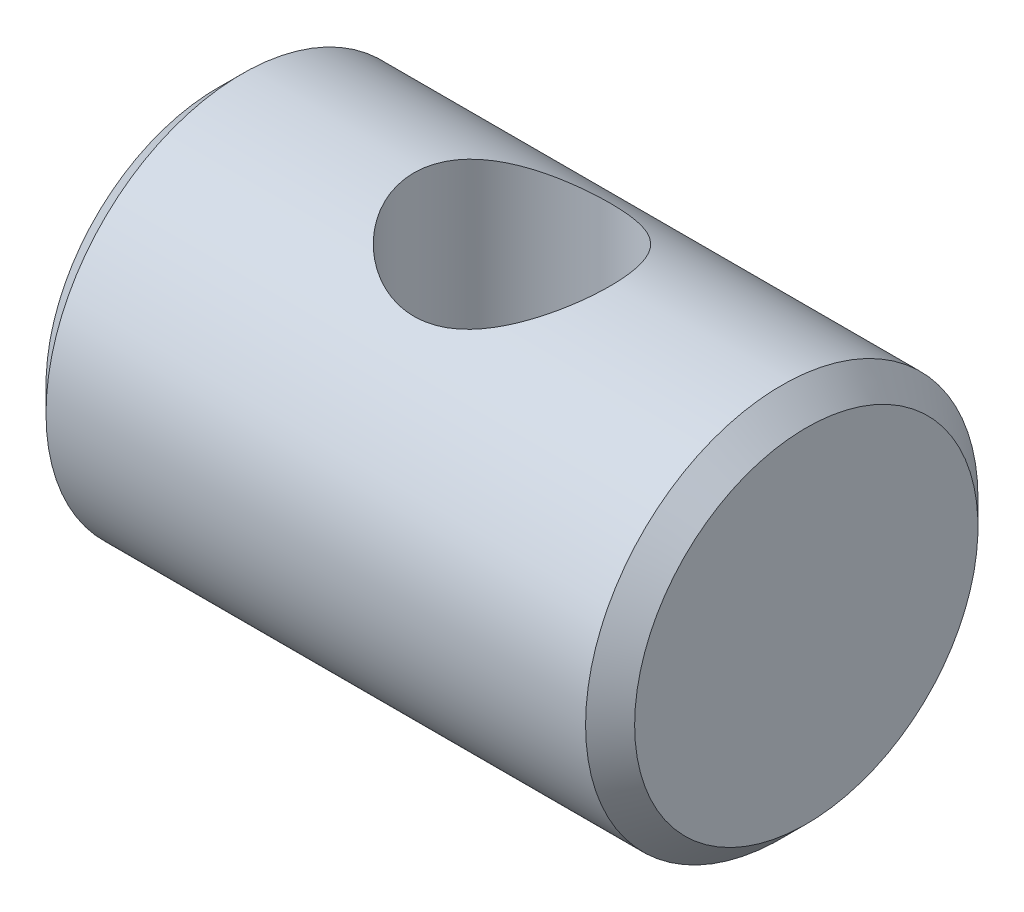
from build123d import *

# Parameters (mm, degrees)
SZKIC1_W                               = 24
SZKIC1_H                               = 8
WYTNIJ_WYCI_GNI_CIE1_REACH             = 10
SZKIC2_R                               = 4
WYTNIJ_WYCI_GNI_CIE1_DIRECTION_2_REACH = 10
SFAZOWANIE1_SIZE                       = 1


with BuildPart() as part:
    # Szkic1 → Obrót1 (revolve)
    with BuildSketch(Plane.XY):
        with Locations((12, 4)):
            Rectangle(SZKIC1_W, SZKIC1_H)
    revolve(axis=Axis((0, 0, 0), (1, 0, 0)))

    # Szkic2 → Wytnij-wyciągnięcie1 (cut, up to next)
    with BuildSketch(Plane(origin=(0, 0, 0), x_dir=(1, 0, 0), z_dir=(0, 1, 0)), mode=Mode.PRIVATE) as wytnij_wyci_gni_cie1_sk1:
        with Locations((12, 0)):
            Circle(SZKIC2_R)
    wytnij_wyci_gni_cie1_tool1 = extrude(wytnij_wyci_gni_cie1_sk1.sketch, amount=-WYTNIJ_WYCI_GNI_CIE1_REACH, mode=Mode.PRIVATE) & part.part
    add(wytnij_wyci_gni_cie1_tool1.solids().sort_by_distance((12, 0, 0))[0], mode=Mode.SUBTRACT)

    # Szkic2 → Wytnij-wyciągnięcie1 direction 2 (cut, up to next)
    with BuildSketch(Plane(origin=(0, 0, 0), x_dir=(1, 0, 0), z_dir=(0, 1, 0)), mode=Mode.PRIVATE) as wytnij_wyci_gni_cie1_direction_2_sk1:
        with Locations((12, 0)):
            Circle(SZKIC2_R)
    wytnij_wyci_gni_cie1_direction_2_tool1 = extrude(wytnij_wyci_gni_cie1_direction_2_sk1.sketch, amount=WYTNIJ_WYCI_GNI_CIE1_DIRECTION_2_REACH, mode=Mode.PRIVATE) & part.part
    add(wytnij_wyci_gni_cie1_direction_2_tool1.solids().sort_by_distance((12, 0, 0))[0], mode=Mode.SUBTRACT)

    # Sfazowanie1
    sfazowanie1_edges = [part.edges().sort_by_distance(p)[0] for p in [
        (0, -8, 0),
        (24, -8, 0),
    ]]
    chamfer(sfazowanie1_edges, length=SFAZOWANIE1_SIZE)


solid = part.part
